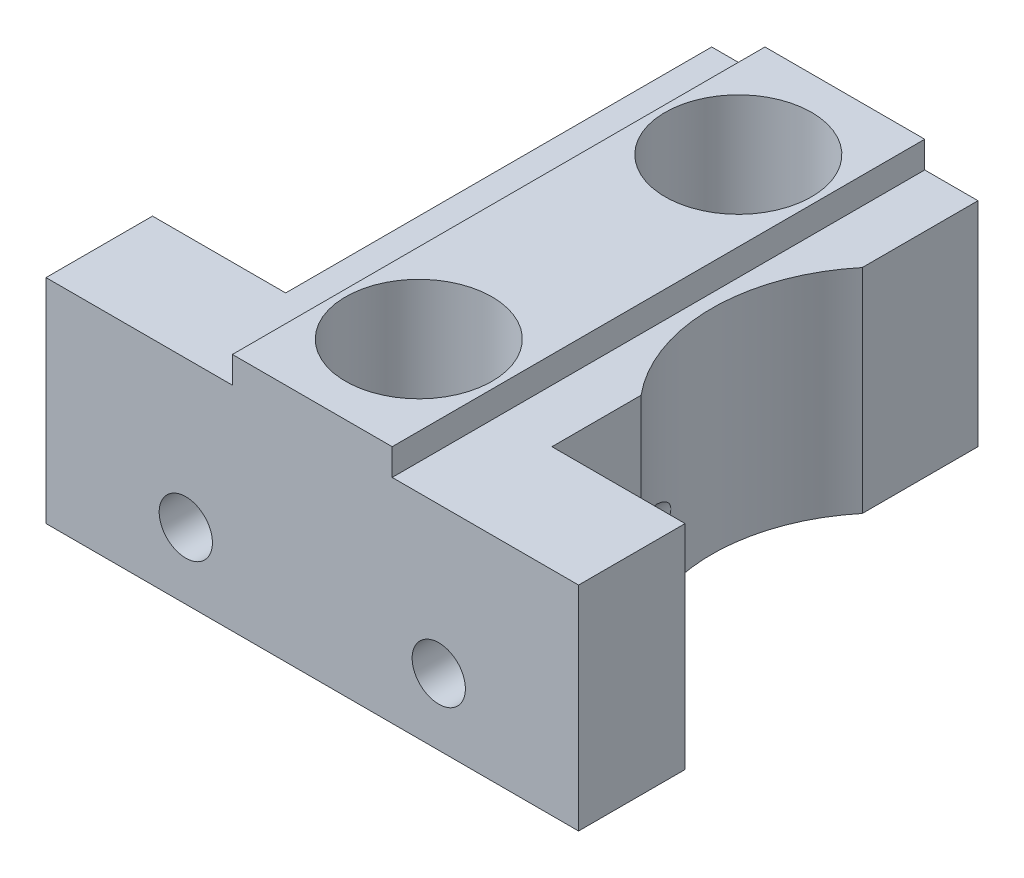
from build123d import *

# Parameters (mm, degrees)
BOSS_EXTRUDE1_DEPTH = 8
SKETCH5_W           = 6
SKETCH5_H           = 20
BOSS_EXTRUDE2_DEPTH = 1
SKETCH6_R           = 6.5
CUT_EXTRUDE3_DEPTH  = 10
SKETCH2_R           = 2.75
CUT_EXTRUDE1_DEPTH  = 10
SKETCH3_R           = 1
CUT_EXTRUDE2_DEPTH  = 12


with BuildPart() as part:
    # Sketch1 → Boss-Extrude1 (new body)
    with BuildSketch(Plane(origin=(0, 0, 0), x_dir=(1, 0, 0), z_dir=(0, 1, 0))):
        Polygon((-10, 0), (10, 0), (10, 4), (5, 4), (5, 20), (-5, 20), (-5, 4), (-10, 4), align=None)
    extrude(amount=BOSS_EXTRUDE1_DEPTH)

    # Sketch5 → Boss-Extrude2 (add)
    with BuildSketch(Plane(origin=(0, 8, 0), x_dir=(1, 0, 0), z_dir=(0, 1, 0))):
        with Locations((0, 10)):
            Rectangle(SKETCH5_W, SKETCH5_H)
    extrude(amount=BOSS_EXTRUDE2_DEPTH)

    # Sketch6 → Cut-Extrude3 (cut, through all)
    with BuildSketch(Plane.XZ):
        with Locations((10, -11.5)):
            Circle(SKETCH6_R)
    extrude(amount=-CUT_EXTRUDE3_DEPTH, mode=Mode.SUBTRACT)

    # Sketch2 → Cut-Extrude1 (cut, through all)
    with BuildSketch(Plane.XZ):
        with Locations((0, -4)):
            Circle(SKETCH2_R)
        with Locations((0, -16)):
            Circle(SKETCH2_R)
    extrude(amount=-CUT_EXTRUDE1_DEPTH, mode=Mode.SUBTRACT)

    # Sketch3 → Cut-Extrude2 (cut)
    with BuildSketch(Plane.XY):
        with Locations((-4.75, 2.5)):
            Circle(SKETCH3_R)
        with Locations((4.75, 2.5)):
            Circle(SKETCH3_R)
    extrude(amount=-CUT_EXTRUDE2_DEPTH, mode=Mode.SUBTRACT)


solid = part.part
